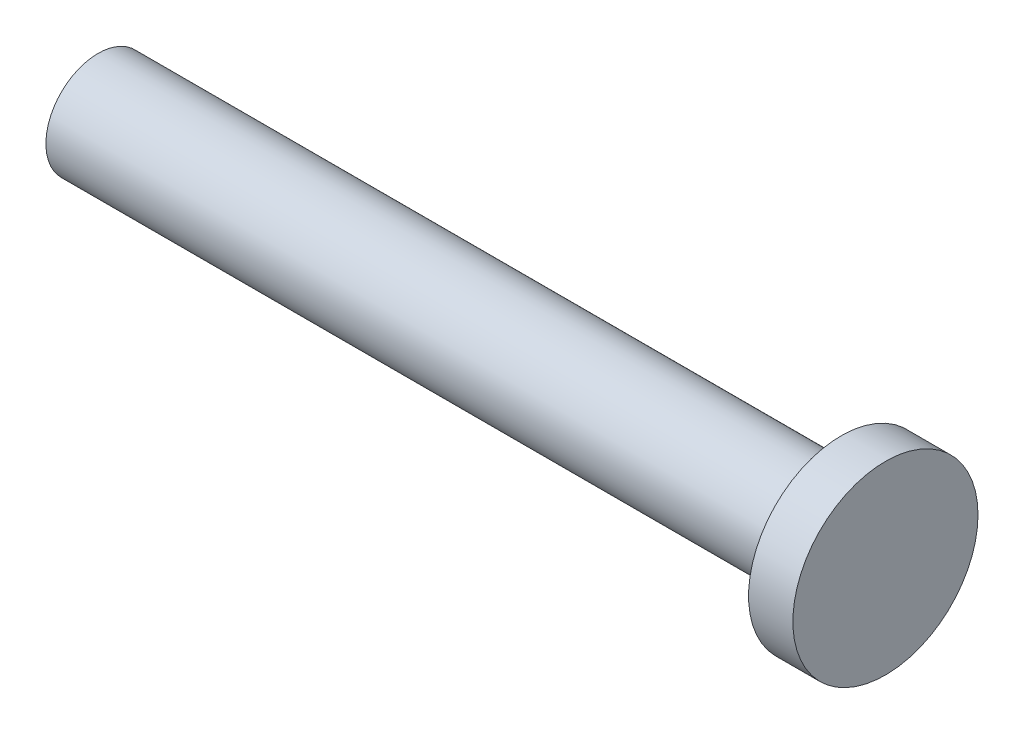
from build123d import *

# Parameters (mm, degrees)
SKETCH1_R           = 10
BOSS_EXTRUDE1_DEPTH = 142.5
SKETCH2_R           = 17.75
BOSS_EXTRUDE2_DEPTH = 8.5


with BuildPart() as part:
    # Sketch1 → Boss-Extrude1 (new body)
    with BuildSketch(Plane(origin=(0, 0, 0), x_dir=(0, 0, -1), z_dir=(1, 0, 0))):
        Circle(SKETCH1_R)
    extrude(amount=BOSS_EXTRUDE1_DEPTH)

    # Sketch2 → Boss-Extrude2 (add)
    with BuildSketch(Plane(origin=(142.5, 0, 0), x_dir=(0, 0, -1), z_dir=(1, 0, 0))):
        Circle(SKETCH2_R)
    extrude(amount=BOSS_EXTRUDE2_DEPTH)


solid = part.part
